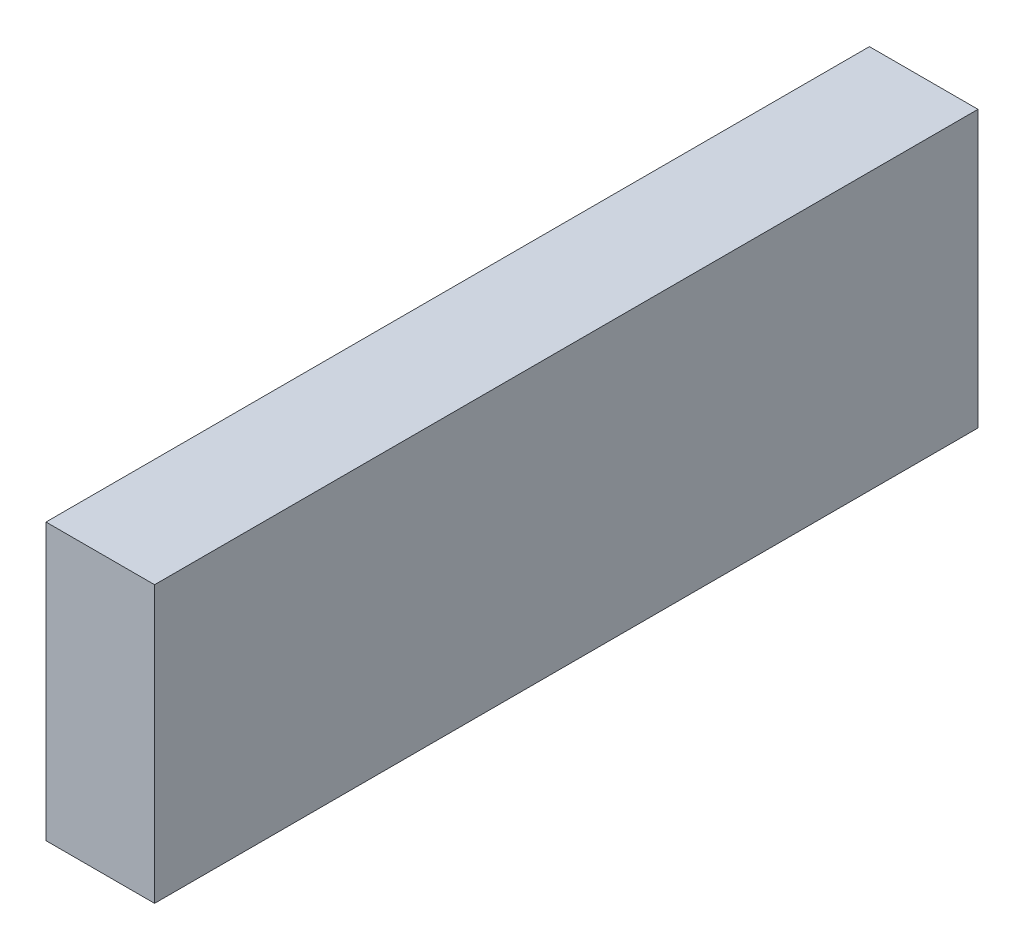
from build123d import *

# Parameters (mm, degrees)
SKETCH1_W           = 24
SKETCH1_H           = 182
BOSS_EXTRUDE1_DEPTH = 61


with BuildPart() as part:
    # Sketch1 → Boss-Extrude1 (new body)
    with BuildSketch(Plane(origin=(0, 0, 0), x_dir=(1, 0, 0), z_dir=(0, 1, 0))):
        Rectangle(SKETCH1_W, SKETCH1_H)
    extrude(amount=BOSS_EXTRUDE1_DEPTH)


solid = part.part
